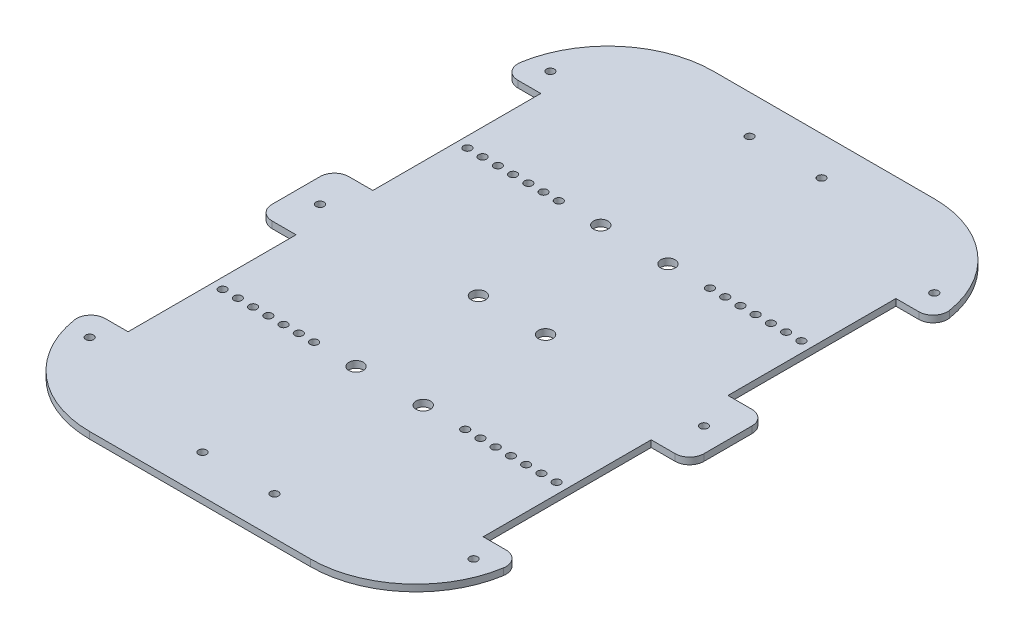
from build123d import *

# Parameters (mm, degrees)
BOSS_EXTRUDE4_DEPTH = 2.8
SKETCH5_R           = 1.65
SKETCH5_R_2         = 3
CUT_EXTRUDE1_DEPTH  = 3.8


with BuildPart() as part:
    # Sketch2 → Boss-Extrude4 (new body)
    with BuildSketch(Plane(origin=(0, 0, 0), x_dir=(1, 0, 0), z_dir=(0, 1, 0))):
        with BuildLine():
            Line((46, -130), (-46, -130))
            ThreePointArc((-46, -130), (-74.550970119, -119.478980051), (-89.448061775, -92.947368421))
            ThreePointArc((-89.448061775, -92.947368421), (-88.08864154, -88.106685893), (-83.523326079, -86))
            Line((-83.523326079, -86), (-74, -86))
            Line((-74, -86), (-74, -16))
            Line((-74, -16), (-84, -16))
            ThreePointArc((-84, -16), (-88.242640687, -14.242640687), (-90, -10))
            Line((-90, -10), (-90, 10))
            ThreePointArc((-90, 10), (-88.242640687, 14.242640687), (-84, 16))
            Line((-84, 16), (-74, 16))
            Line((-74, 16), (-74, 86))
            Line((-74, 86), (-83.523326079, 86))
            ThreePointArc((-83.523326079, 86), (-88.08864154, 88.106685893), (-89.448061775, 92.947368421))
            ThreePointArc((-89.448061775, 92.947368421), (-74.550970119, 119.478980051), (-46, 130))
            Line((-46, 130), (46, 130))
            ThreePointArc((46, 130), (74.550970119, 119.478980051), (89.448061775, 92.947368421))
            ThreePointArc((89.448061775, 92.947368421), (88.08864154, 88.106685893), (83.523326079, 86))
            Line((83.523326079, 86), (74, 86))
            Line((74, 86), (74, 16))
            Line((74, 16), (84, 16))
            ThreePointArc((84, 16), (88.242640687, 14.242640687), (90, 10))
            Line((90, 10), (90, -10))
            ThreePointArc((90, -10), (88.242640687, -14.242640687), (84, -16))
            Line((84, -16), (74, -16))
            Line((74, -16), (74, -86))
            Line((74, -86), (83.523326079, -86))
            ThreePointArc((83.523326079, -86), (88.08864154, -88.106685893), (89.448061775, -92.947368421))
            ThreePointArc((89.448061775, -92.947368421), (74.550970119, -119.478980051), (46, -130))
        make_face()
    extrude(amount=BOSS_EXTRUDE4_DEPTH)

    # Sketch5 → Cut-Extrude1 (cut, through all)
    with BuildSketch(Plane(origin=(0, 2.8, 0), x_dir=(1, 0, 0), z_dir=(0, 1, 0))):
        with Locations((-69.6, -51)):
            Circle(SKETCH5_R)
        with Locations((-63.25, -51)):
            Circle(SKETCH5_R)
        with Locations((-56.9, -51)):
            Circle(SKETCH5_R)
        with Locations((-50.55, -51)):
            Circle(SKETCH5_R)
        with Locations((-44.2, -51)):
            Circle(SKETCH5_R)
        with Locations((-37.85, -51)):
            Circle(SKETCH5_R)
        with Locations((-31.5, -51)):
            Circle(SKETCH5_R)
        with Locations((31.5, -51)):
            Circle(SKETCH5_R)
        with Locations((37.85, -51)):
            Circle(SKETCH5_R)
        with Locations((44.2, -51)):
            Circle(SKETCH5_R)
        with Locations((50.55, -51)):
            Circle(SKETCH5_R)
        with Locations((56.9, -51)):
            Circle(SKETCH5_R)
        with Locations((63.25, -51)):
            Circle(SKETCH5_R)
        with Locations((69.6, -51)):
            Circle(SKETCH5_R)
        with Locations((69.6, 51)):
            Circle(SKETCH5_R)
        with Locations((63.25, 51)):
            Circle(SKETCH5_R)
        with Locations((56.9, 51)):
            Circle(SKETCH5_R)
        with Locations((50.55, 51)):
            Circle(SKETCH5_R)
        with Locations((44.2, 51)):
            Circle(SKETCH5_R)
        with Locations((37.85, 51)):
            Circle(SKETCH5_R)
        with Locations((31.5, 51)):
            Circle(SKETCH5_R)
        with Locations((-31.5, 51)):
            Circle(SKETCH5_R)
        with Locations((-37.85, 51)):
            Circle(SKETCH5_R)
        with Locations((-44.2, 51)):
            Circle(SKETCH5_R)
        with Locations((-50.55, 51)):
            Circle(SKETCH5_R)
        with Locations((-56.9, 51)):
            Circle(SKETCH5_R)
        with Locations((-63.25, 51)):
            Circle(SKETCH5_R)
        with Locations((-69.6, 51)):
            Circle(SKETCH5_R)
        with Locations((-14, -51)):
            Circle(SKETCH5_R_2)
        with Locations((14, -51)):
            Circle(SKETCH5_R_2)
        with Locations((14, 51)):
            Circle(SKETCH5_R_2)
        with Locations((-14, 51)):
            Circle(SKETCH5_R_2)
        with Locations((-14, 0)):
            Circle(SKETCH5_R_2)
        with Locations((14, 0)):
            Circle(SKETCH5_R_2)
        with Locations((-80, 96)):
            Circle(SKETCH5_R)
        with Locations((-80, 0)):
            Circle(SKETCH5_R)
        with Locations((80, 0)):
            Circle(SKETCH5_R)
        with Locations((-80, -96)):
            Circle(SKETCH5_R)
        with Locations((80, -96)):
            Circle(SKETCH5_R)
        with Locations((80, 96)):
            Circle(SKETCH5_R)
        with Locations((-15, -114)):
            Circle(SKETCH5_R)
        with Locations((15, -114)):
            Circle(SKETCH5_R)
        with Locations((15, 114)):
            Circle(SKETCH5_R)
        with Locations((-15, 114)):
            Circle(SKETCH5_R)
    extrude(amount=-CUT_EXTRUDE1_DEPTH, mode=Mode.SUBTRACT)


solid = part.part
